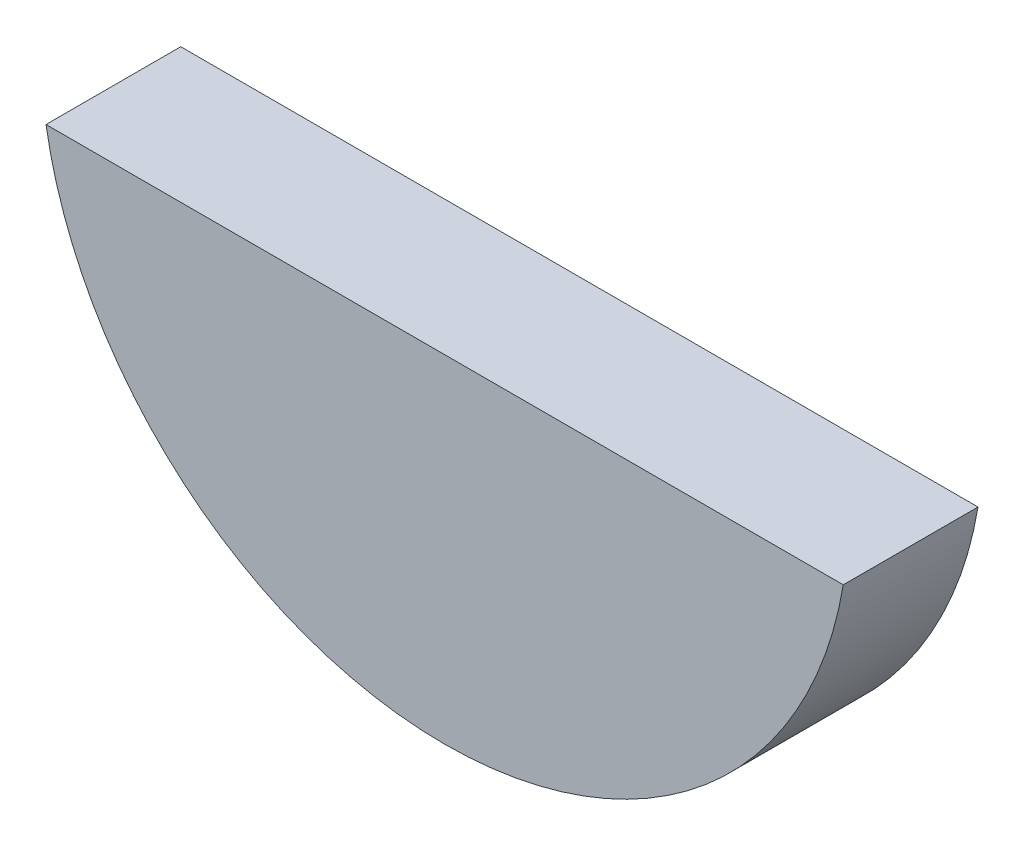
from build123d import *

# Parameters (mm, degrees)
BOSS_EXTRUDE1_DEPTH = 1.5875


with BuildPart() as part:
    # Sketch1 → Boss-Extrude1 (new body, symmetric)
    with BuildSketch(Plane.XY):
        with BuildLine():
            Line((-9.393914517, -1.5748), (9.393914517, -1.5748))
            ThreePointArc((9.393914517, -1.5748), (0, -9.525), (-9.393914517, -1.5748))
        make_face()
    extrude(amount=BOSS_EXTRUDE1_DEPTH, both=True)


solid = part.part
